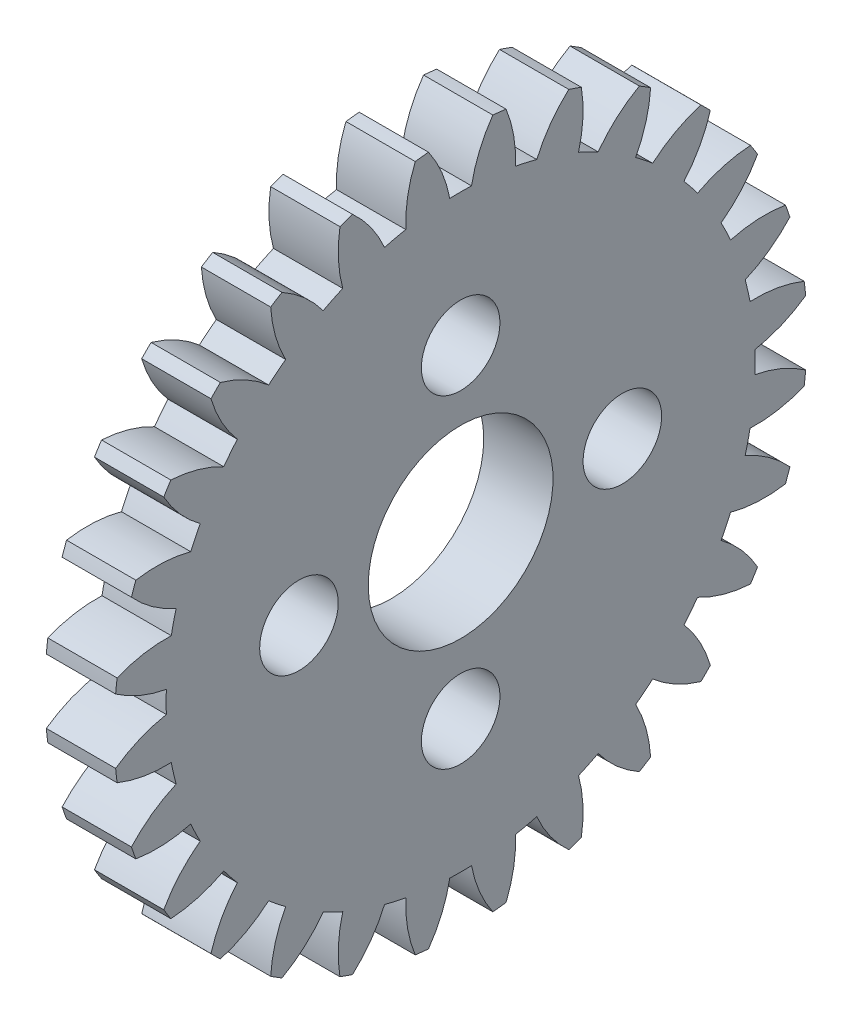
from build123d import *

# Parameters (mm, degrees)
BASPROSKE_W          = 3
BASPROSKE_H          = 15
TOOTHCUT_DEPTH       = 22.424285286
TEETHCUTS_COUNT      = 28
TEETHCUTS_ANGLE      = 347.142857143
BORSKE_R             = 4
BORE_DEPTH           = 50.0000508
M3_CLEARANCE_HOLE1_D = 3.4
CIRPATTERN1_COUNT    = 4


with BuildPart() as part:
    # BasProSke → Base-Revolve (revolve)
    with BuildSketch(Plane(origin=(0, 0, 0), x_dir=(1, 0, 0), z_dir=(0, 1, 0)), mode=Mode.PRIVATE) as base_revolve_sk:
        with Locations((1.5, 7.5)):
            Rectangle(BASPROSKE_W, BASPROSKE_H)
    revolve(base_revolve_sk.sketch.rotate(Axis((-10, 0, 0), (1, 0, 0)), 180), axis=Axis((-10, 0, 0), (1, 0, 0)))

    # TooCutSke → ToothCut (cut, through all)
    with BuildSketch(Plane(origin=(0, 0, 0), x_dir=(0, 0, -1), z_dir=(1, 0, 0))):
        with BuildLine():
            ThreePointArc((0.471336039, 12.740284272), (0, 12.749), (-0.471336039, 12.740284272))
            ThreePointArc((-0.471336039, 12.740284272), (-0.81983923, 13.900763331), (-1.409805137, 14.959114099))
            ThreePointArc((-1.409805137, 14.959114099), (0, 15.0254), (1.409805137, 14.959114099))
            ThreePointArc((1.409805137, 14.959114099), (0.81983923, 13.900763331), (0.471336039, 12.740284272))
        make_face()
    toothcut = extrude(amount=TOOTHCUT_DEPTH, mode=Mode.SUBTRACT)

    # TeethCuts: ToothCut ×28 about axis
    teethcuts_axis = Axis((-10, 0, 0), (1, 0, 0))
    for i in range(1, TEETHCUTS_COUNT):
        add(toothcut.rotate(teethcuts_axis, i * TEETHCUTS_ANGLE / (TEETHCUTS_COUNT - 1)), mode=Mode.SUBTRACT)

    # BorSke → Bore (cut, symmetric)
    with BuildSketch(Plane(origin=(0, 0, 0), x_dir=(0, 0, -1), z_dir=(1, 0, 0))):
        with Locations(Location((0, 0, 0), (0, 0, 180))):
            Circle(BORSKE_R)
    extrude(amount=BORE_DEPTH, both=True, mode=Mode.SUBTRACT)

    # M3 Clearance Hole1 (through all)
    with Locations(Plane(origin=(3, 0, 0), x_dir=(0, 0, -1), z_dir=(1, 0, 0))):
        with Locations((0, 7)):
            m3_clearance_hole1 = Hole(M3_CLEARANCE_HOLE1_D / 2)

    # CirPattern1: M3 Clearance Hole1 ×4 about axis
    cirpattern1_axis = Axis((0, 0, 0), (1, 0, 0))
    for i in range(1, CIRPATTERN1_COUNT):
        add(m3_clearance_hole1.rotate(cirpattern1_axis, i * 360 / CIRPATTERN1_COUNT), mode=Mode.SUBTRACT)


solid = part.part
